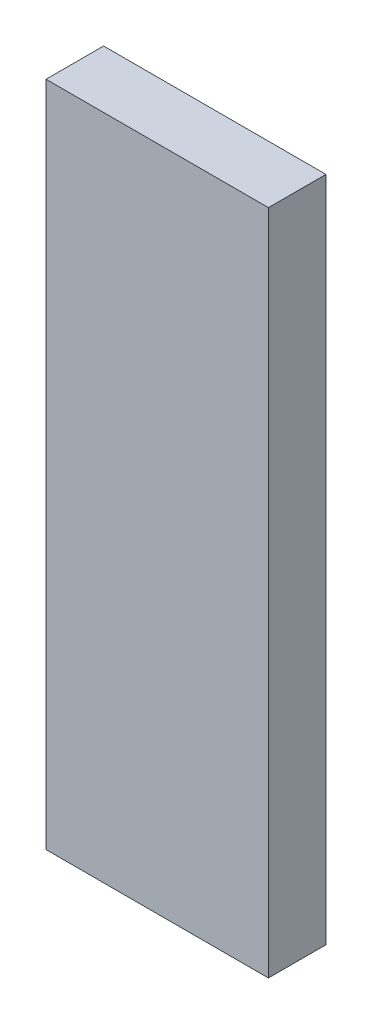
from build123d import *

# Parameters (mm, degrees)
SKETCH1_W             = 12.7
SKETCH1_H             = 38.1
BOSS_EXTRUDE1_DEPTH   = 3.28676
BOSS_EXTRUDE1_2_DEPTH = 3.28676


with BuildPart() as part:
    # Sketch1 → Boss-Extrude1 (new body)
    with BuildSketch(Plane.XY):
        with Locations((22.465, 0)):
            Rectangle(SKETCH1_W, SKETCH1_H)
    extrude(amount=BOSS_EXTRUDE1_DEPTH)


with BuildPart() as body_2:
    # Sketch1 → Boss-Extrude1 2 (new body)
    with BuildSketch(Plane.XY):
        with Locations((-22.465, 0)):
            Rectangle(SKETCH1_W, SKETCH1_H)
    extrude(amount=BOSS_EXTRUDE1_2_DEPTH)


solid = body_2.part
